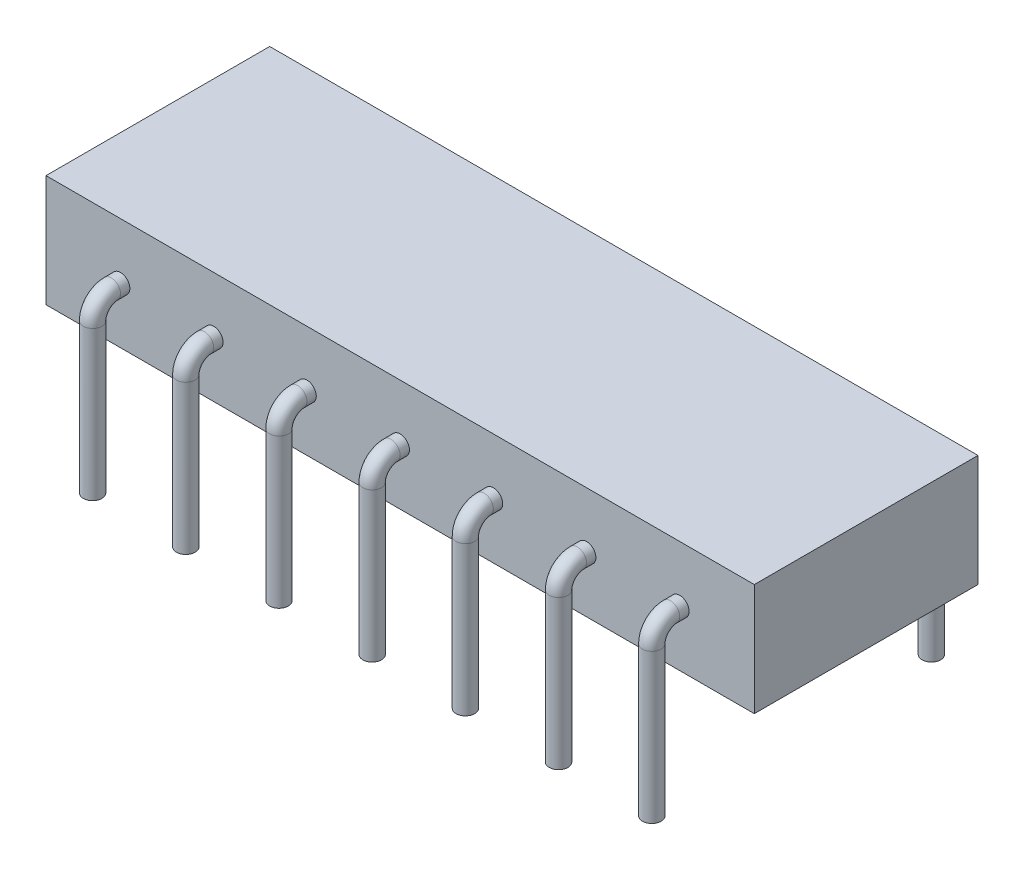
from build123d import *

# Parameters (mm, degrees)
SKETCH1_W               = 19
SKETCH1_H               = 6
BOSS_EXTRUDE1_DEPTH     = 3
SKETCH3_R               = 0.25
LPATTERN1_COUNT         = 7
LPATTERN1_PITCH         = 2.5
MIRROR1_COPY_1_SKETCH_R = 0.25
MIRROR1_COPY_2_SKETCH_R = 0.25
MIRROR1_COPY_3_SKETCH_R = 0.25
MIRROR1_COPY_4_SKETCH_R = 0.25
MIRROR1_COPY_5_SKETCH_R = 0.25
MIRROR1_COPY_6_SKETCH_R = 0.25


with BuildPart() as part:
    # Sketch1 → Boss-Extrude1 (new body)
    with BuildSketch(Plane(origin=(0, 0, 0), x_dir=(1, 0, 0), z_dir=(0, 1, 0))):
        with Locations((9.5, 3)):
            Rectangle(SKETCH1_W, SKETCH1_H)
    extrude(amount=BOSS_EXTRUDE1_DEPTH)

    # Sweep1: sweep along a path in Sketch4
    with BuildLine(Plane(origin=(2, 0, 0), x_dir=(0, 0, -1), z_dir=(1, 0, 0))) as sweep1_path:
        Line((0, 1.5), (-0.25, 1.5))
        ThreePointArc((-0.25, 1.5), (-0.603553391, 1.353553391), (-0.75, 1))
        Line((-0.75, 1), (-0.75, -3))
    # Sketch3 → Sweep1 (sweep)
    with BuildSketch(Plane.XY):
        with Locations((2, 1.5)):
            Circle(SKETCH3_R)
    sweep1 = sweep(path=sweep1_path.line)

    # LPattern1: Sweep1 ×7
    with Locations(*[(i * LPATTERN1_PITCH, 0, 0) for i in range(1, LPATTERN1_COUNT)]):
        add(sweep1)

    # Mirror1: Sweep1 across plane
    add(sweep1.mirror(Plane.XY.offset(-3)))

    # Mirror1 copy 1: sweep along a path in Mirror1 copy 1 path
    with BuildLine(Plane(origin=(4.5, 0, -6), x_dir=(0, 0, 1), z_dir=(1, 0, 0))) as mirror1_copy_1_path:
        Line((0, -1.5), (-0.25, -1.5))
        ThreePointArc((-0.25, -1.5), (-0.603553391, -1.353553391), (-0.75, -1))
        Line((-0.75, -1), (-0.75, 3))
    # Mirror1 copy 1 sketch → Mirror1 copy 1 (sweep)
    with BuildSketch(Plane(origin=(2.5, 0, -6), x_dir=(1, 0, 0), z_dir=(0, 0, -1))):
        with Locations((2, -1.5)):
            Circle(MIRROR1_COPY_1_SKETCH_R)
    sweep(path=mirror1_copy_1_path.line)

    # Mirror1 copy 2: sweep along a path in Mirror1 copy 2 path
    with BuildLine(Plane(origin=(7, 0, -6), x_dir=(0, 0, 1), z_dir=(1, 0, 0))) as mirror1_copy_2_path:
        Line((0, -1.5), (-0.25, -1.5))
        ThreePointArc((-0.25, -1.5), (-0.603553391, -1.353553391), (-0.75, -1))
        Line((-0.75, -1), (-0.75, 3))
    # Mirror1 copy 2 sketch → Mirror1 copy 2 (sweep)
    with BuildSketch(Plane(origin=(5, 0, -6), x_dir=(1, 0, 0), z_dir=(0, 0, -1))):
        with Locations((2, -1.5)):
            Circle(MIRROR1_COPY_2_SKETCH_R)
    sweep(path=mirror1_copy_2_path.line)

    # Mirror1 copy 3: sweep along a path in Mirror1 copy 3 path
    with BuildLine(Plane(origin=(9.5, 0, -6), x_dir=(0, 0, 1), z_dir=(1, 0, 0))) as mirror1_copy_3_path:
        Line((0, -1.5), (-0.25, -1.5))
        ThreePointArc((-0.25, -1.5), (-0.603553391, -1.353553391), (-0.75, -1))
        Line((-0.75, -1), (-0.75, 3))
    # Mirror1 copy 3 sketch → Mirror1 copy 3 (sweep)
    with BuildSketch(Plane(origin=(7.5, 0, -6), x_dir=(1, 0, 0), z_dir=(0, 0, -1))):
        with Locations((2, -1.5)):
            Circle(MIRROR1_COPY_3_SKETCH_R)
    sweep(path=mirror1_copy_3_path.line)

    # Mirror1 copy 4: sweep along a path in Mirror1 copy 4 path
    with BuildLine(Plane(origin=(12, 0, -6), x_dir=(0, 0, 1), z_dir=(1, 0, 0))) as mirror1_copy_4_path:
        Line((0, -1.5), (-0.25, -1.5))
        ThreePointArc((-0.25, -1.5), (-0.603553391, -1.353553391), (-0.75, -1))
        Line((-0.75, -1), (-0.75, 3))
    # Mirror1 copy 4 sketch → Mirror1 copy 4 (sweep)
    with BuildSketch(Plane(origin=(10, 0, -6), x_dir=(1, 0, 0), z_dir=(0, 0, -1))):
        with Locations((2, -1.5)):
            Circle(MIRROR1_COPY_4_SKETCH_R)
    sweep(path=mirror1_copy_4_path.line)

    # Mirror1 copy 5: sweep along a path in Mirror1 copy 5 path
    with BuildLine(Plane(origin=(14.5, 0, -6), x_dir=(0, 0, 1), z_dir=(1, 0, 0))) as mirror1_copy_5_path:
        Line((0, -1.5), (-0.25, -1.5))
        ThreePointArc((-0.25, -1.5), (-0.603553391, -1.353553391), (-0.75, -1))
        Line((-0.75, -1), (-0.75, 3))
    # Mirror1 copy 5 sketch → Mirror1 copy 5 (sweep)
    with BuildSketch(Plane(origin=(12.5, 0, -6), x_dir=(1, 0, 0), z_dir=(0, 0, -1))):
        with Locations((2, -1.5)):
            Circle(MIRROR1_COPY_5_SKETCH_R)
    sweep(path=mirror1_copy_5_path.line)

    # Mirror1 copy 6: sweep along a path in Mirror1 copy 6 path
    with BuildLine(Plane(origin=(17, 0, -6), x_dir=(0, 0, 1), z_dir=(1, 0, 0))) as mirror1_copy_6_path:
        Line((0, -1.5), (-0.25, -1.5))
        ThreePointArc((-0.25, -1.5), (-0.603553391, -1.353553391), (-0.75, -1))
        Line((-0.75, -1), (-0.75, 3))
    # Mirror1 copy 6 sketch → Mirror1 copy 6 (sweep)
    with BuildSketch(Plane(origin=(15, 0, -6), x_dir=(1, 0, 0), z_dir=(0, 0, -1))):
        with Locations((2, -1.5)):
            Circle(MIRROR1_COPY_6_SKETCH_R)
    sweep(path=mirror1_copy_6_path.line)


solid = part.part
